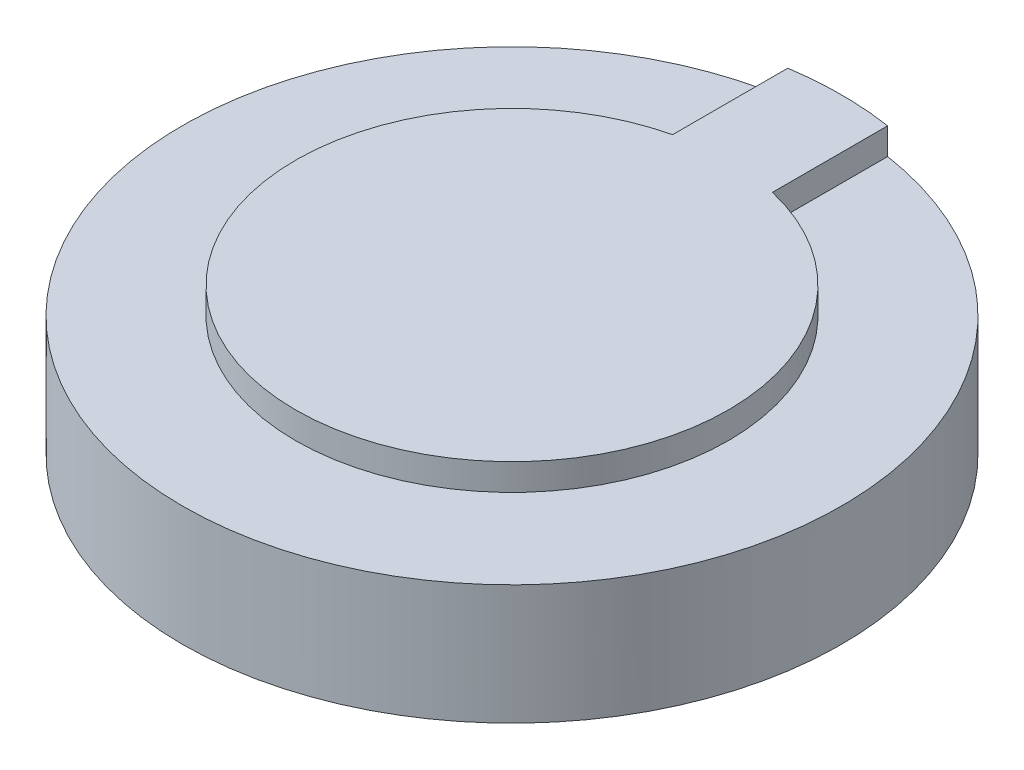
from build123d import *

# Parameters (mm, degrees)
BOSS_EXTRUDE1_DEPTH = 0.8


with BuildPart() as part:
    # Sketch1 → Revolve1 (revolve)
    with BuildSketch(Plane(origin=(0, 0, 0), x_dir=(0, 0, -1), z_dir=(1, 0, 0))):
        Polygon((0, 0), (9.9, 0), (9.9, 3.6), (6.5, 3.6), (6.5, 4.4), (0, 4.4), align=None)
    revolve(axis=Axis((0, 4.4, 0), (0, -1, 0)))

    # Sketch2 → Boss-Extrude1 (add)
    with BuildSketch(Plane(origin=(0, 3.6, 0), x_dir=(1, 0, 0), z_dir=(0, 1, 0))):
        with BuildLine():
            Line((-1.5, 6.32455532), (1.5, 6.32455532))
            Line((1.5, 6.32455532), (1.5, 9.785703858))
            ThreePointArc((1.5, 9.785703858), (0, 9.9), (-1.5, 9.785703858))
            Line((-1.5, 9.785703858), (-1.5, 6.32455532))
        make_face()
    extrude(amount=BOSS_EXTRUDE1_DEPTH)


solid = part.part
